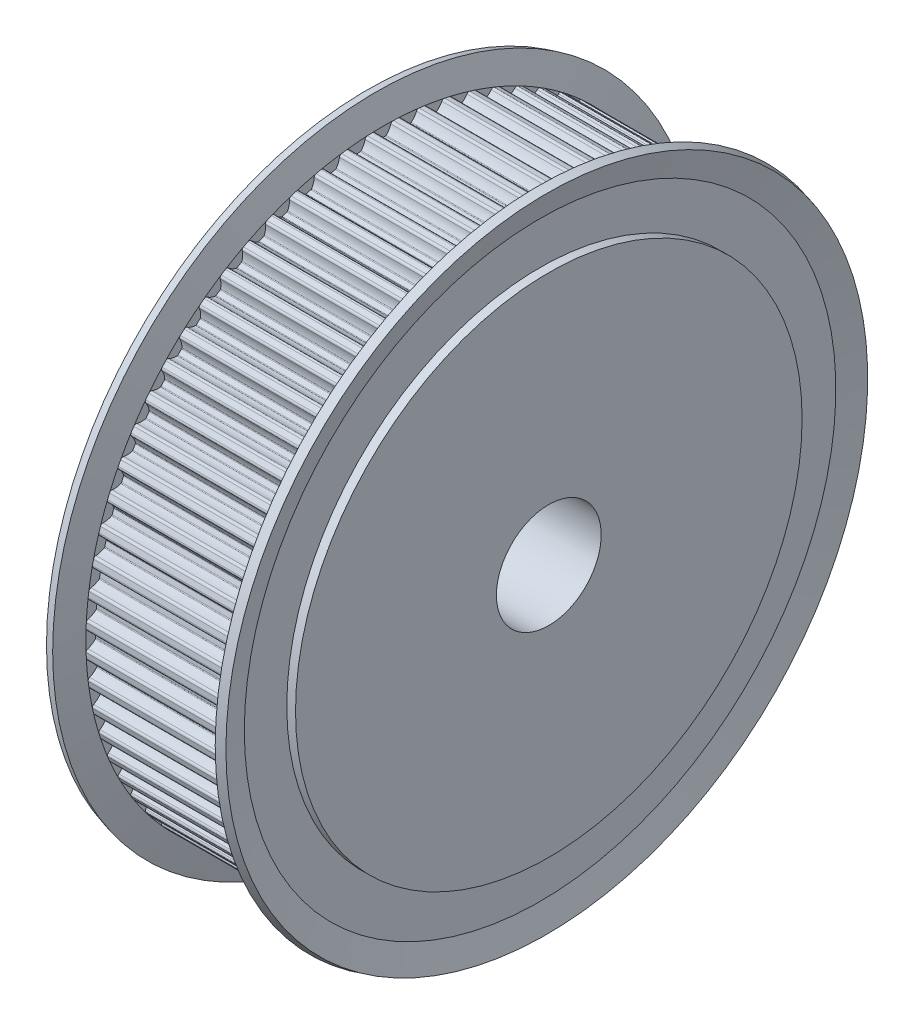
from build123d import *

# Parameters (mm, degrees)
SKETCH_2_W          = 21
SKETCH_2_H          = 6
SKETCH_3_R          = 38.995
CUT_EXTRUDE_1_DEPTH = 17


with BuildPart() as part:
    # ｽｹｯﾁ1 → 回転1 (revolve)
    with BuildSketch(Plane.XY):
        Polygon((0, 0), (0, 29), (1, 29), (1, 33.863347502), (0.22888685, 36.741180955), (1.194812677, 37), (2, 33.995), (19, 33.995), (19.805187323, 37), (20.77111315, 36.741180955), (20, 33.863347502), (20, 29), (21, 29), (21, 0), align=None)
    revolve(axis=Axis((21, 0, 0), (-1, 0, 0)))

    # ｽｹｯﾁ2 → ｶｯﾄ - 回転1 (revolve, cut)
    with BuildSketch(Plane.XY):
        with Locations((10.5, 3)):
            Rectangle(SKETCH_2_W, SKETCH_2_H)
    revolve(axis=Axis((21, 0, 0), (-1, 0, 0)), mode=Mode.SUBTRACT)

    # ｽｹｯﾁ3 → ｶｯﾄ - 押し出し1 (cut)
    with BuildSketch(Plane(origin=(2, 0, 0), x_dir=(0, 0, -1), z_dir=(1, 0, 0))):
        Circle(SKETCH_3_R)
        with BuildLine():
            ThreePointArc((-33.777168623, -0.911681599), (-33.922614353, -1.016968917), (-33.974202204, -1.18895314))
            ThreePointArc((-33.974202204, -1.18895314), (-33.962644297, -1.482840979), (-33.948544212, -1.776617823))
            ThreePointArc((-33.948544212, -1.776617823), (-33.882163306, -1.943451535), (-33.728094586, -2.035661844))
            ThreePointArc((-33.728094586, -2.035661844), (-33.250950848, -2.205234651), (-32.83260935, -2.490561611))
            ThreePointArc((-32.83260935, -2.490561611), (-32.797994707, -2.535862252), (-32.782784237, -2.590807344))
            ThreePointArc((-32.782784237, -2.590807344), (-32.759862676, -2.866116264), (-32.73462912, -3.141222911))
            ThreePointArc((-32.73462912, -3.141222911), (-32.740067244, -3.197974916), (-32.766289768, -3.248598454))
            ThreePointArc((-32.766289768, -3.248598454), (-33.128729197, -3.60223486), (-33.569178012, -3.852086595))
            ThreePointArc((-33.569178012, -3.852086595), (-33.704893882, -3.969649693), (-33.741296014, -4.145475642))
            ThreePointArc((-33.741296014, -4.145475642), (-33.704168075, -4.43723781), (-33.664517306, -4.728667842))
            ThreePointArc((-33.664517306, -4.728667842), (-33.583848484, -4.889081224), (-33.422329383, -4.967512671))
            ThreePointArc((-33.422329383, -4.967512671), (-32.93222222, -5.094854328), (-32.490604858, -5.342634543))
            ThreePointArc((-32.490604858, -5.342634543), (-32.452173557, -5.384745989), (-32.432232107, -5.43815645))
            ThreePointArc((-32.432232107, -5.43815645), (-32.385402958, -5.710420323), (-32.336288235, -5.982281187))
            ThreePointArc((-32.336288235, -5.982281187), (-32.336759592, -6.039290865), (-32.358470133, -6.092006878))
            ThreePointArc((-32.358470133, -6.092006878), (-32.688708926, -6.475886269), (-33.105705687, -6.763174885))
            ThreePointArc((-33.105705687, -6.763174885), (-33.230658816, -6.892119033), (-33.251598189, -7.070448561))
            ThreePointArc((-33.251598189, -7.070448561), (-33.189182784, -7.357864578), (-33.124283096, -7.644729844))
            ThreePointArc((-33.124283096, -7.644729844), (-33.029940296, -7.797502053), (-32.862200073, -7.861557728))
            ThreePointArc((-32.862200073, -7.861557728), (-32.362859356, -7.945699158), (-31.901327011, -8.154047007))
            ThreePointArc((-31.901327011, -8.154047007), (-31.859371701, -8.192648697), (-31.834851107, -8.244117901))
            ThreePointArc((-31.834851107, -8.244117901), (-31.764470885, -8.511263973), (-31.691848915, -8.77780937))
            ThreePointArc((-31.691848915, -8.77780937), (-31.68734954, -8.834643506), (-31.704383001, -8.889051453))
            ThreePointArc((-31.704383001, -8.889051453), (-31.999907843, -9.300252273), (-32.390278951, -9.622791331))
            ThreePointArc((-32.390278951, -9.622791331), (-32.503518375, -9.762135195), (-32.508835621, -9.941611117))
            ThreePointArc((-32.508835621, -9.941611117), (-32.421607769, -10.222493564), (-32.331953091, -10.502610835))
            ThreePointArc((-32.331953091, -10.502610835), (-32.224654318, -10.646579182), (-32.051969577, -10.695771583))
            ThreePointArc((-32.051969577, -10.695771583), (-31.547195595, -10.736072418), (-31.069260809, -10.903402246))
            ThreePointArc((-31.069260809, -10.903402246), (-31.024100792, -10.938200398), (-30.995187669, -10.987336637))
            ThreePointArc((-30.995187669, -10.987336637), (-30.90179195, -11.247332096), (-30.806215367, -11.506533786))
            ThreePointArc((-30.806215367, -11.506533786), (-30.796779693, -11.56275958), (-30.80900643, -11.618445115))
            ThreePointArc((-30.80900643, -11.618445115), (-31.067568184, -12.0538378), (-31.428342635, -12.409172525))
            ThreePointArc((-31.428342635, -12.409172525), (-31.529006529, -12.557855605), (-31.518661189, -12.73711199))
            ThreePointArc((-31.518661189, -12.73711199), (-31.407284746, -13.009323191), (-31.2935574, -13.280560616))
            ThreePointArc((-31.2935574, -13.280560616), (-31.174119263, -13.414629416), (-30.99780424, -13.448584158))
            ThreePointArc((-30.99780424, -13.448584158), (-30.491438626, -13.444737685), (-30.000738771, -13.569776011))
            ThreePointArc((-30.000738771, -13.569776011), (-29.952717742, -13.600505791), (-29.919632137, -13.646935107))
            ThreePointArc((-29.919632137, -13.646935107), (-29.803931719, -13.897801232), (-29.686127918, -14.147686533))
            ThreePointArc((-29.686127918, -14.147686533), (-29.67182775, -14.202875997), (-29.679154645, -14.259415261))
            ThreePointArc((-29.679154645, -14.259415261), (-29.89878552, -14.715686288), (-30.227217655, -15.101112423))
            ThreePointArc((-30.227217655, -15.101112423), (-30.314539909, -15.25800316), (-30.288610707, -15.435675769))
            ThreePointArc((-30.288610707, -15.435675769), (-30.153933318, -15.697144023), (-30.016998841, -15.957437311))
            ThreePointArc((-30.016998841, -15.957437311), (-29.886330337, -16.08058622), (-29.707726895, -16.099044887))
            ThreePointArc((-29.707726895, -16.099044887), (-29.203623396, -16.05108038), (-28.703892992, -16.132875587))
            ThreePointArc((-28.703892992, -16.132875587), (-28.653376423, -16.159303124), (-28.616370138, -16.20267216))
            ThreePointArc((-28.616370138, -16.20267216), (-28.479245572, -16.442499708), (-28.340111111, -16.681166842))
            ThreePointArc((-28.340111111, -16.681166842), (-28.32105529, -16.734899884), (-28.323426541, -16.791862514))
            ThreePointArc((-28.323426541, -16.791862514), (-28.502455004, -17.265539439), (-28.796045267, -17.678123706))
            ThreePointArc((-28.796045267, -17.678123706), (-28.869361332, -17.842028072), (-28.828045612, -18.016764725))
            ThreePointArc((-28.828045612, -18.016764725), (-28.671092251, -18.265500106), (-28.511992797, -18.512868274))
            ThreePointArc((-28.511992797, -18.512868274), (-28.371088391, -18.624160053), (-28.191555811, -18.626982163))
            ThreePointArc((-28.191555811, -18.626982163), (-27.693550959, -18.535264661), (-27.188593259, -18.573194239))
            ThreePointArc((-27.188593259, -18.573194239), (-27.135965609, -18.595118401), (-27.095320283, -18.635097095))
            ThreePointArc((-27.095320283, -18.635097095), (-26.93781517, -18.862060833), (-26.778408946, -19.0876934))
            ThreePointArc((-26.778408946, -19.0876934), (-26.754742496, -19.139561146), (-26.752140102, -19.196513683))
            ThreePointArc((-26.752140102, -19.196513683), (-26.889203644, -19.683991484), (-27.14571762, -20.120593821))
            ThreePointArc((-27.14571762, -20.120593821), (-27.204469487, -20.290264398), (-27.148081684, -20.460735223))
            ThreePointArc((-27.148081684, -20.460735223), (-26.970046861, -20.694844704), (-26.789993272, -20.92740513))
            ThreePointArc((-26.789993272, -20.92740513), (-26.639925332, -21.025992783), (-26.460829964, -21.013156858))
            ThreePointArc((-26.460829964, -21.013156858), (-25.97271388, -20.878384387), (-25.466371917, -20.872159667))
            ThreePointArc((-25.466371917, -20.872159667), (-25.412033713, -20.889413599), (-25.368058681, -20.925697689))
            ThreePointArc((-25.368058681, -20.925697689), (-25.191371729, -21.138070286), (-25.01290692, -21.348951085))
            ThreePointArc((-25.01290692, -21.348951085), (-24.984809955, -21.398558794), (-24.977253724, -21.455067799))
            ThreePointArc((-24.977253724, -21.455067799), (-25.071309207, -21.952636467), (-25.288794664, -22.409934061))
            ThreePointArc((-25.288794664, -22.409934061), (-25.332535204, -22.584079556), (-25.261504461, -22.748987172))
            ThreePointArc((-25.261504461, -22.748987172), (-25.063743129, -22.966689038), (-24.864105721, -23.182671798))
            ThreePointArc((-24.864105721, -23.182671798), (-24.706016355, -23.267805011), (-24.528721224, -23.239408742))
            ThreePointArc((-24.528721224, -23.239408742), (-24.054208764, -23.062607), (-23.550336105, -23.012275357))
            ThreePointArc((-23.550336105, -23.012275357), (-23.494700895, -23.024727746), (-23.447730834, -23.057041088))
            ThreePointArc((-23.447730834, -23.057041088), (-23.253206738, -23.253206261), (-23.057041569, -23.447730362))
            ThreePointArc((-23.057041569, -23.447730362), (-23.024727926, -23.494700483), (-23.012275364, -23.55033588))
            ThreePointArc((-23.012275364, -23.55033588), (-23.062606969, -24.054208629), (-23.239408718, -24.528721178))
            ThreePointArc((-23.239408718, -24.528721178), (-23.267805032, -24.706016236), (-23.182671936, -24.864105592))
            ThreePointArc((-23.182671936, -24.864105592), (-22.966689178, -25.063743001), (-22.748987313, -25.261504334))
            ThreePointArc((-22.748987313, -25.261504334), (-22.584079676, -25.332535194), (-22.409934104, -25.288794692))
            ThreePointArc((-22.409934104, -25.288794692), (-21.952636596, -25.071309249), (-21.455068018, -24.977253737))
            ThreePointArc((-21.455068018, -24.977253737), (-21.398559218, -24.984809812), (-21.348951598, -25.012906482))
            ThreePointArc((-21.348951598, -25.012906482), (-21.138070545, -25.191371512), (-20.925697689, -25.368058681))
            ThreePointArc((-20.925697689, -25.368058681), (-20.889413652, -25.412033614), (-20.872159693, -25.466371694))
            ThreePointArc((-20.872159693, -25.466371694), (-20.878384368, -25.972713748), (-21.013156842, -26.460829925))
            ThreePointArc((-21.013156842, -26.460829925), (-21.025992812, -26.63992522), (-20.92740528, -26.789993155))
            ThreePointArc((-20.92740528, -26.789993155), (-20.694844855, -26.970046745), (-20.460735375, -27.14808157))
            ThreePointArc((-20.460735375, -27.14808157), (-20.290264514, -27.204469488), (-20.120593854, -27.145717645))
            ThreePointArc((-20.120593854, -27.145717645), (-19.683991605, -26.889203695), (-19.196513902, -26.752140134))
            ThreePointArc((-19.196513902, -26.752140134), (-19.139561581, -26.75474239), (-19.087693949, -26.778408555))
            ThreePointArc((-19.087693949, -26.778408555), (-18.862061109, -26.937814976), (-18.635097095, -27.095320283))
            ThreePointArc((-18.635097095, -27.095320283), (-18.59511846, -27.135965519), (-18.573194282, -27.188593049))
            ThreePointArc((-18.573194282, -27.188593049), (-18.535264654, -27.693550822), (-18.626982145, -28.191555754))
            ThreePointArc((-18.626982145, -28.191555754), (-18.624160093, -28.371088278), (-18.512868425, -28.511992699))
            ThreePointArc((-18.512868425, -28.511992699), (-18.265500262, -28.671092152), (-18.016764886, -28.828045512))
            ThreePointArc((-18.016764886, -28.828045512), (-17.842028188, -28.869361343), (-17.678123736, -28.796045296))
            ThreePointArc((-17.678123736, -28.796045296), (-17.26553942, -28.502454994), (-16.791862432, -28.323426522))
            ThreePointArc((-16.791862432, -28.323426522), (-16.734900176, -28.321055246), (-16.681167424, -28.340110769))
            ThreePointArc((-16.681167424, -28.340110769), (-16.4425, -28.479245403), (-16.20267216, -28.616370138))
            ThreePointArc((-16.20267216, -28.616370138), (-16.159303151, -28.653376389), (-16.132875613, -28.703892908))
            ThreePointArc((-16.132875613, -28.703892908), (-16.051080382, -29.203623322), (-16.099044874, -29.707726837))
            ThreePointArc((-16.099044874, -29.707726837), (-16.080586272, -29.886330223), (-15.957437479, -30.016998752))
            ThreePointArc((-15.957437479, -30.016998752), (-15.697144191, -30.15393323), (-15.435675938, -30.288610621))
            ThreePointArc((-15.435675938, -30.288610621), (-15.258003253, -30.314539926), (-15.101112423, -30.227217655))
            ThreePointArc((-15.101112423, -30.227217655), (-14.715686195, -29.89878546), (-14.25941505, -29.679154575))
            ThreePointArc((-14.25941505, -29.679154575), (-14.202876223, -29.671827735), (-14.147687142, -29.686127628))
            ThreePointArc((-14.147687142, -29.686127628), (-13.897801537, -29.803931577), (-13.646935107, -29.919632137))
            ThreePointArc((-13.646935107, -29.919632137), (-13.600505865, -29.952717665), (-13.56977609, -30.000738572))
            ThreePointArc((-13.56977609, -30.000738572), (-13.444737702, -30.491438487), (-13.448584149, -30.997804174))
            ThreePointArc((-13.448584149, -30.997804174), (-13.41462948, -31.174119151), (-13.280560791, -31.293557326))
            ThreePointArc((-13.280560791, -31.293557326), (-13.009323371, -31.407284671), (-12.737112175, -31.518661114))
            ThreePointArc((-12.737112175, -31.518661114), (-12.557855701, -31.529006556), (-12.409172525, -31.428342635))
            ThreePointArc((-12.409172525, -31.428342635), (-12.053837714, -31.067568116), (-11.618444913, -30.809006343))
            ThreePointArc((-11.618444913, -30.809006343), (-11.562759807, -30.796779699), (-11.506534418, -30.806215131))
            ThreePointArc((-11.506534418, -30.806215131), (-11.247332413, -30.901791835), (-10.987336637, -30.995187669))
            ThreePointArc((-10.987336637, -30.995187669), (-10.938200432, -31.024100762), (-10.903402286, -31.069260728))
            ThreePointArc((-10.903402286, -31.069260728), (-10.736072434, -31.547195518), (-10.695771579, -32.051969511))
            ThreePointArc((-10.695771579, -32.051969511), (-10.646579255, -32.224654212), (-10.502611015, -32.331953032))
            ThreePointArc((-10.502611015, -32.331953032), (-10.222493745, -32.421607712), (-9.941611298, -32.508835565))
            ThreePointArc((-9.941611298, -32.508835565), (-9.762135284, -32.503518408), (-9.622791331, -32.390278951))
            ThreePointArc((-9.622791331, -32.390278951), (-9.300252247, -31.999907819), (-8.889051391, -31.704382968))
            ThreePointArc((-8.889051391, -31.704382968), (-8.834643807, -31.687349574), (-8.77781002, -31.691848735))
            ThreePointArc((-8.77781002, -31.691848735), (-8.511264298, -31.764470798), (-8.244117901, -31.834851107))
            ThreePointArc((-8.244117901, -31.834851107), (-8.192648733, -31.859371675), (-8.154047054, -31.901326935))
            ThreePointArc((-8.154047054, -31.901326935), (-7.94569918, -32.362859285), (-7.86155773, -32.862200013))
            ThreePointArc((-7.86155773, -32.862200013), (-7.797502014, -33.029940342), (-7.644729668, -33.124283136))
            ThreePointArc((-7.644729668, -33.124283136), (-7.357864588, -33.189182781), (-7.070448756, -33.251598148))
            ThreePointArc((-7.070448756, -33.251598148), (-6.892119123, -33.230658859), (-6.763174885, -33.105705687))
            ThreePointArc((-6.763174885, -33.105705687), (-6.475886248, -32.688708903), (-6.092006826, -32.358470099))
            ThreePointArc((-6.092006826, -32.358470099), (-6.039290835, -32.336759585), (-5.982281187, -32.336288235))
            ThreePointArc((-5.982281187, -32.336288235), (-5.710420323, -32.385402958), (-5.43815645, -32.432232107))
            ThreePointArc((-5.43815645, -32.432232107), (-5.384746029, -32.452173533), (-5.342634599, -32.490604782))
            ThreePointArc((-5.342634599, -32.490604782), (-5.094854358, -32.932222145), (-4.96751268, -33.422329317))
            ThreePointArc((-4.96751268, -33.422329317), (-4.889081184, -33.583848524), (-4.728667664, -33.664517331))
            ThreePointArc((-4.728667664, -33.664517331), (-4.437237815, -33.704168074), (-4.14547583, -33.741295991))
            ThreePointArc((-4.14547583, -33.741295991), (-3.969649775, -33.70489393), (-3.852086595, -33.569178012))
            ThreePointArc((-3.852086595, -33.569178012), (-3.602234844, -33.128729175), (-3.24859841, -32.766289734))
            ThreePointArc((-3.24859841, -32.766289734), (-3.197975213, -32.740067332), (-3.141223582, -32.734629056))
            ThreePointArc((-3.141223582, -32.734629056), (-2.866116936, -32.759862617), (-2.590808017, -32.782784183))
            ThreePointArc((-2.590808017, -32.782784183), (-2.535862458, -32.797994605), (-2.490561468, -32.832609511))
            ThreePointArc((-2.490561468, -32.832609511), (-2.205234616, -33.250950918), (-2.035661857, -33.728094528))
            ThreePointArc((-2.035661857, -33.728094528), (-1.943451489, -33.882163345), (-1.776617644, -33.948544221))
            ThreePointArc((-1.776617644, -33.948544221), (-1.482840984, -33.962644297), (-1.18895333, -33.974202198))
            ThreePointArc((-1.18895333, -33.974202198), (-1.016968994, -33.922614408), (-0.911681599, -33.777168623))
            ThreePointArc((-0.911681599, -33.777168623), (-0.701168253, -33.316619809), (-0.380466189, -32.924738112))
            ThreePointArc((-0.380466189, -32.924738112), (-0.332321063, -32.894203395), (-0.276259369, -32.883839584))
            ThreePointArc((-0.276259369, -32.883839584), (-3.37e-07, -32.885), (0.276258695, -32.883839589))
            ThreePointArc((0.276258695, -32.883839589), (0.332320839, -32.894203307), (0.38046633, -32.924738245))
            ThreePointArc((0.38046633, -32.924738245), (0.701168287, -33.316619863), (0.911681579, -33.77716856))
            ThreePointArc((0.911681579, -33.77716856), (1.016969036, -33.922614437), (1.188953498, -33.974202192))
            ThreePointArc((1.188953498, -33.974202192), (1.482841158, -33.962644289), (1.776617823, -33.948544212))
            ThreePointArc((1.776617823, -33.948544212), (1.943451535, -33.882163306), (2.035661844, -33.728094586))
            ThreePointArc((2.035661844, -33.728094586), (2.205234649, -33.250950852), (2.490561605, -32.832609357))
            ThreePointArc((2.490561605, -32.832609357), (2.535862248, -32.797994709), (2.590807344, -32.782784237))
            ThreePointArc((2.590807344, -32.782784237), (2.866116264, -32.759862676), (3.141222911, -32.73462912))
            ThreePointArc((3.141222911, -32.73462912), (3.197974975, -32.740067262), (3.24859855, -32.766289845))
            ThreePointArc((3.24859855, -32.766289845), (3.602234875, -33.128729217), (3.852086567, -33.569177944))
            ThreePointArc((3.852086567, -33.569177944), (3.969649816, -33.704893955), (4.145475998, -33.74129597))
            ThreePointArc((4.145475998, -33.74129597), (4.437237988, -33.704168051), (4.728667842, -33.664517306))
            ThreePointArc((4.728667842, -33.664517306), (4.889081224, -33.583848484), (4.967512671, -33.422329383))
            ThreePointArc((4.967512671, -33.422329383), (5.09485433, -32.932222216), (5.342634548, -32.490604851))
            ThreePointArc((5.342634548, -32.490604851), (5.384745993, -32.452173555), (5.43815645, -32.432232107))
            ThreePointArc((5.43815645, -32.432232107), (5.710419991, -32.385403016), (5.982280524, -32.336288357))
            ThreePointArc((5.982280524, -32.336288357), (6.039290596, -32.336759537), (6.092006982, -32.358470201))
            ThreePointArc((6.092006982, -32.358470201), (6.475886286, -32.688708945), (6.763174852, -33.105705622))
            ThreePointArc((6.763174852, -33.105705622), (6.892119167, -33.230658879), (7.070448921, -33.251598113))
            ThreePointArc((7.070448921, -33.251598113), (7.357864758, -33.189182744), (7.644729844, -33.124283096))
            ThreePointArc((7.644729844, -33.124283096), (7.797502053, -33.029940296), (7.861557728, -32.862200073))
            ThreePointArc((7.861557728, -32.862200073), (7.945699158, -32.362859355), (8.154047009, -31.901327008))
            ThreePointArc((8.154047009, -31.901327008), (8.192648698, -31.8593717), (8.244117901, -31.834851107))
            ThreePointArc((8.244117901, -31.834851107), (8.511263973, -31.764470885), (8.77780937, -31.691848915))
            ThreePointArc((8.77780937, -31.691848915), (8.834643567, -31.687349547), (8.88905156, -31.704383059))
            ThreePointArc((8.88905156, -31.704383059), (9.300252291, -31.999907859), (9.622791292, -32.390278889))
            ThreePointArc((9.622791292, -32.390278889), (9.762135329, -32.503518424), (9.94161146, -32.508835516))
            ThreePointArc((9.94161146, -32.508835516), (10.222493735, -32.421607715), (10.502610835, -32.331953091))
            ThreePointArc((10.502610835, -32.331953091), (10.646579182, -32.224654318), (10.695771583, -32.051969577))
            ThreePointArc((10.695771583, -32.051969577), (10.736072419, -31.547195592), (10.903402248, -31.069260804))
            ThreePointArc((10.903402248, -31.069260804), (10.938200401, -31.02410079), (10.987336637, -30.995187669))
            ThreePointArc((10.987336637, -30.995187669), (11.247332096, -30.90179195), (11.506533786, -30.806215367))
            ThreePointArc((11.506533786, -30.806215367), (11.562759565, -30.796779693), (11.618445087, -30.809006418))
            ThreePointArc((11.618445087, -30.809006418), (12.053837759, -31.067568152), (12.409172481, -31.428342577))
            ThreePointArc((12.409172481, -31.428342577), (12.557855584, -31.529006524), (12.737112019, -31.518661177))
            ThreePointArc((12.737112019, -31.518661177), (13.009323205, -31.40728474), (13.280560616, -31.2935574))
            ThreePointArc((13.280560616, -31.2935574), (13.414629416, -31.174119263), (13.448584158, -30.99780424))
            ThreePointArc((13.448584158, -30.99780424), (13.444737685, -30.491438623), (13.569776013, -30.000738765))
            ThreePointArc((13.569776013, -30.000738765), (13.600505793, -29.95271774), (13.646935107, -29.919632137))
            ThreePointArc((13.646935107, -29.919632137), (13.897801232, -29.803931719), (14.147686533, -29.686127918))
            ThreePointArc((14.147686533, -29.686127918), (14.202875984, -29.67182775), (14.259415236, -29.679154636))
            ThreePointArc((14.259415236, -29.679154636), (14.715686242, -29.89878549), (15.101112366, -30.227217592))
            ThreePointArc((15.101112366, -30.227217592), (15.258003129, -30.314539903), (15.435675788, -30.288610697))
            ThreePointArc((15.435675788, -30.288610697), (15.697144032, -30.153933313), (15.957437311, -30.016998841))
            ThreePointArc((15.957437311, -30.016998841), (16.08058622, -29.886330337), (16.099044887, -29.707726895))
            ThreePointArc((16.099044887, -29.707726895), (16.05108038, -29.203623391), (16.13287559, -28.703892984))
            ThreePointArc((16.13287559, -28.703892984), (16.159303126, -28.653376419), (16.20267216, -28.616370138))
            ThreePointArc((16.20267216, -28.616370138), (16.442499708, -28.479245572), (16.681166842, -28.340111111))
            ThreePointArc((16.681166842, -28.340111111), (16.734899937, -28.321055282), (16.791862618, -28.323426566))
            ThreePointArc((16.791862618, -28.323426566), (17.265539467, -28.502455019), (17.678123675, -28.796045239))
            ThreePointArc((17.678123675, -28.796045239), (17.842028062, -28.869361331), (18.016764743, -28.828045601))
            ThreePointArc((18.016764743, -28.828045601), (18.265500115, -28.671092246), (18.512868274, -28.511992797))
            ThreePointArc((18.512868274, -28.511992797), (18.624160053, -28.371088391), (18.626982163, -28.191555811))
            ThreePointArc((18.626982163, -28.191555811), (18.535264653, -27.693550814), (18.573194298, -27.188592973))
            ThreePointArc((18.573194298, -27.188592973), (18.595118482, -27.135965487), (18.635097095, -27.095320283))
            ThreePointArc((18.635097095, -27.095320283), (18.862060833, -26.93781517), (19.0876934, -26.778408946))
            ThreePointArc((19.0876934, -26.778408946), (19.139561162, -26.754742492), (19.196513716, -26.752140107))
            ThreePointArc((19.196513716, -26.752140107), (19.683991477, -26.88920364), (20.120593782, -27.145717589))
            ThreePointArc((20.120593782, -27.145717589), (20.290264553, -27.204469489), (20.46073551, -27.148081468))
            ThreePointArc((20.46073551, -27.148081468), (20.694844846, -26.970046752), (20.92740513, -26.789993272))
            ThreePointArc((20.92740513, -26.789993272), (21.025992783, -26.639925332), (21.013156858, -26.460829964))
            ThreePointArc((21.013156858, -26.460829964), (20.878384366, -25.972713733), (20.872159701, -25.466371621))
            ThreePointArc((20.872159701, -25.466371621), (20.88941367, -25.412033582), (20.925697689, -25.368058681))
            ThreePointArc((20.925697689, -25.368058681), (21.138070286, -25.191371729), (21.348951085, -25.01290692))
            ThreePointArc((21.348951085, -25.01290692), (21.398558834, -24.984809941), (21.455067884, -24.977253729))
            ThreePointArc((21.455067884, -24.977253729), (21.952636488, -25.071309214), (22.409934027, -25.288794643))
            ThreePointArc((22.409934027, -25.288794643), (22.584079714, -25.332535191), (22.748987438, -25.261504221))
            ThreePointArc((22.748987438, -25.261504221), (22.96668917, -25.063743008), (23.182671798, -24.864105721))
            ThreePointArc((23.182671798, -24.864105721), (23.267805011, -24.706016355), (23.239408742, -24.528721224))
            ThreePointArc((23.239408742, -24.528721224), (23.062606966, -24.054208617), (23.012275366, -23.550335804))
            ThreePointArc((23.012275366, -23.550335804), (23.024727806, -23.494700757), (23.057041088, -23.447730834))
            ThreePointArc((23.057041088, -23.447730834), (23.253206261, -23.253206738), (23.447730362, -23.057041569))
            ThreePointArc((23.447730362, -23.057041569), (23.494700505, -23.024727916), (23.55033593, -23.012275362))
            ThreePointArc((23.55033593, -23.012275362), (24.054208634, -23.06260697), (24.528721142, -23.239408699))
            ThreePointArc((24.528721142, -23.239408699), (24.706016384, -23.267805006), (24.864105824, -23.182671687))
            ThreePointArc((24.864105824, -23.182671687), (25.063743116, -22.966689052), (25.261504334, -22.748987313))
            ThreePointArc((25.261504334, -22.748987313), (25.332535194, -22.584079676), (25.288794692, -22.409934104))
            ThreePointArc((25.288794692, -22.409934104), (25.071309202, -21.952636451), (24.97725372, -21.455067715))
            ThreePointArc((24.97725372, -21.455067715), (24.984809861, -21.398559074), (25.012906482, -21.348951598))
            ThreePointArc((25.012906482, -21.348951598), (25.191371295, -21.138070803), (25.368058252, -20.925698209))
            ThreePointArc((25.368058252, -20.925698209), (25.41203333, -20.889413807), (25.466371722, -20.872159689))
            ThreePointArc((25.466371722, -20.872159689), (25.972713741, -20.878384367), (26.460829886, -21.013156826))
            ThreePointArc((26.460829886, -21.013156826), (26.639925218, -21.025992812), (26.789993179, -20.927405249))
            ThreePointArc((26.789993179, -20.927405249), (26.970046757, -20.694844839), (27.14808157, -20.460735375))
            ThreePointArc((27.14808157, -20.460735375), (27.204469488, -20.290264514), (27.145717645, -20.120593854))
            ThreePointArc((27.145717645, -20.120593854), (26.889203638, -19.68399147), (26.752140092, -19.196513611))
            ThreePointArc((26.752140092, -19.196513611), (26.754742425, -19.139561438), (26.778408555, -19.087693949))
            ThreePointArc((26.778408555, -19.087693949), (26.937814783, -18.862061386), (27.095319901, -18.635097651))
            ThreePointArc((27.095319901, -18.635097651), (27.135965247, -18.595118641), (27.188593069, -18.573194278))
            ThreePointArc((27.188593069, -18.573194278), (27.69355082, -18.535264654), (28.19155573, -18.626982138))
            ThreePointArc((28.19155573, -18.626982138), (28.371088423, -18.624160042), (28.511992879, -18.512868147))
            ThreePointArc((28.511992879, -18.512868147), (28.671092241, -18.265500122), (28.828045512, -18.016764886))
            ThreePointArc((28.828045512, -18.016764886), (28.869361343, -17.842028188), (28.796045296, -17.678123736))
            ThreePointArc((28.796045296, -17.678123736), (28.502454996, -17.265539424), (28.323426524, -16.791862441))
            ThreePointArc((28.323426524, -16.791862441), (28.321055246, -16.73490018), (28.340110769, -16.681167424))
            ThreePointArc((28.340110769, -16.681167424), (28.479245235, -16.442500292), (28.616369806, -16.202672747))
            ThreePointArc((28.616369806, -16.202672747), (28.653376086, -16.159303392), (28.703892812, -16.132875641))
            ThreePointArc((28.703892812, -16.132875641), (29.20362326, -16.051080385), (29.707726813, -16.099044868))
            ThreePointArc((29.707726813, -16.099044868), (29.886330236, -16.080586266), (30.016998777, -15.957437433))
            ThreePointArc((30.016998777, -15.957437433), (30.153933242, -15.697144168), (30.288610621, -15.435675938))
            ThreePointArc((30.288610621, -15.435675938), (30.314539926, -15.258003253), (30.227217655, -15.101112423))
            ThreePointArc((30.227217655, -15.101112423), (29.898785463, -14.715686199), (29.679154578, -14.259415059))
            ThreePointArc((29.679154578, -14.259415059), (29.671827735, -14.202876227), (29.686127628, -14.147687142))
            ThreePointArc((29.686127628, -14.147687142), (29.803931434, -13.897801843), (29.919631857, -13.64693572))
            ThreePointArc((29.919631857, -13.64693572), (29.952717427, -13.600506091), (30.00073859, -13.569776083))
            ThreePointArc((30.00073859, -13.569776083), (30.491438487, -13.444737702), (30.997804156, -13.448584146))
            ThreePointArc((30.997804156, -13.448584146), (31.174119161, -13.414629474), (31.293557341, -13.280560755))
            ThreePointArc((31.293557341, -13.280560755), (31.407284679, -13.009323353), (31.518661114, -12.737112175))
            ThreePointArc((31.518661114, -12.737112175), (31.529006556, -12.557855701), (31.428342635, -12.409172525))
            ThreePointArc((31.428342635, -12.409172525), (31.06756812, -12.053837719), (30.809006348, -11.618444924))
            ThreePointArc((30.809006348, -11.618444924), (30.796779699, -11.562759814), (30.806215131, -11.506534418))
            ThreePointArc((30.806215131, -11.506534418), (30.901791719, -11.24733273), (30.995187444, -10.987337272))
            ThreePointArc((30.995187444, -10.987337272), (31.024100504, -10.938200725), (31.069260634, -10.903402334))
            ThreePointArc((31.069260634, -10.903402334), (31.547195458, -10.736072447), (32.051969493, -10.695771578))
            ThreePointArc((32.051969493, -10.695771578), (32.224654221, -10.646579249), (32.331953044, -10.502610978))
            ThreePointArc((32.331953044, -10.502610978), (32.421607718, -10.222493726), (32.508835565, -9.941611298))
            ThreePointArc((32.508835565, -9.941611298), (32.503518408, -9.762135284), (32.390278951, -9.622791331))
            ThreePointArc((32.390278951, -9.622791331), (31.999907821, -9.30025225), (31.704382971, -8.889051397))
            ThreePointArc((31.704382971, -8.889051397), (31.687349574, -8.83464381), (31.691848735, -8.77781002))
            ThreePointArc((31.691848735, -8.77781002), (31.76447071, -8.511264624), (31.834850938, -8.244118554))
            ThreePointArc((31.834850938, -8.244118554), (31.859371444, -8.192649045), (31.901326848, -8.154047107))
            ThreePointArc((31.901326848, -8.154047107), (32.362859224, -7.945699198), (32.862199989, -7.861557731))
            ThreePointArc((32.862199989, -7.861557731), (33.029940316, -7.797502036), (33.124283127, -7.644729709))
            ThreePointArc((33.124283127, -7.644729709), (33.189182777, -7.357864609), (33.251598148, -7.070448756))
            ThreePointArc((33.251598148, -7.070448756), (33.230658859, -6.892119123), (33.105705687, -6.763174885))
            ThreePointArc((33.105705687, -6.763174885), (32.688708904, -6.475886249), (32.3584701, -6.092006829))
            ThreePointArc((32.3584701, -6.092006829), (32.336759586, -6.039290836), (32.336288235, -5.982281187))
            ThreePointArc((32.336288235, -5.982281187), (32.385402899, -5.710420655), (32.432231995, -5.438157115))
            ThreePointArc((32.432231995, -5.438157115), (32.45217333, -5.384746361), (32.490604699, -5.342634661))
            ThreePointArc((32.490604699, -5.342634661), (32.932222089, -5.094854381), (33.4223293, -4.967512682))
            ThreePointArc((33.4223293, -4.967512682), (33.583848503, -4.889081205), (33.664517325, -4.728667706))
            ThreePointArc((33.664517325, -4.728667706), (33.704168071, -4.437237836), (33.741295991, -4.14547583))
            ThreePointArc((33.741295991, -4.14547583), (33.70489393, -3.969649775), (33.569178012, -3.852086595))
            ThreePointArc((33.569178012, -3.852086595), (33.128729175, -3.602234844), (32.766289734, -3.24859841))
            ThreePointArc((32.766289734, -3.24859841), (32.740067332, -3.197975213), (32.734629056, -3.141223582))
            ThreePointArc((32.734629056, -3.141223582), (32.759862647, -2.8661166), (32.782784237, -2.590807344))
            ThreePointArc((32.782784237, -2.590807344), (32.79799473, -2.535862207), (32.832609426, -2.490561543))
            ThreePointArc((32.832609426, -2.490561543), (33.250950856, -2.205234647), (33.728094503, -2.035661862))
            ThreePointArc((33.728094503, -2.035661862), (33.882163324, -1.943451514), (33.948544219, -1.776617686))
            ThreePointArc((33.948544219, -1.776617686), (33.962644296, -1.482841005), (33.974202198, -1.18895333))
            ThreePointArc((33.974202198, -1.18895333), (33.922614408, -1.016968994), (33.777168623, -0.911681599))
            ThreePointArc((33.777168623, -0.911681599), (33.316619811, -0.701168254), (32.924738115, -0.380466191))
            ThreePointArc((32.924738115, -0.380466191), (32.894203395, -0.332321065), (32.883839584, -0.276259369))
            ThreePointArc((32.883839584, -0.276259369), (32.885, 0), (32.883839584, 0.276259369))
            ThreePointArc((32.883839584, 0.276259369), (32.894203415, 0.332321115), (32.924738188, 0.380466269))
            ThreePointArc((32.924738188, 0.380466269), (33.31661982, 0.70116826), (33.777168543, 0.911681574))
            ThreePointArc((33.777168543, 0.911681574), (33.922614419, 1.01696901), (33.974202194, 1.188953453))
            ThreePointArc((33.974202194, 1.188953453), (33.96264429, 1.482841135), (33.948544212, 1.776617823))
            ThreePointArc((33.948544212, 1.776617823), (33.882163306, 1.943451535), (33.728094586, 2.035661844))
            ThreePointArc((33.728094586, 2.035661844), (33.250950854, 2.205234648), (32.832609359, 2.490561603))
            ThreePointArc((32.832609359, 2.490561603), (32.79799471, 2.535862246), (32.782784237, 2.590807344))
            ThreePointArc((32.782784237, 2.590807344), (32.759862647, 2.8661166), (32.734629056, 3.141223582))
            ThreePointArc((32.734629056, 3.141223582), (32.740067348, 3.197975269), (32.766289807, 3.248598502))
            ThreePointArc((32.766289807, 3.248598502), (33.128729188, 3.602234854), (33.569177934, 3.852086563))
            ThreePointArc((33.569177934, 3.852086563), (33.704893936, 3.969649784), (33.741295978, 4.145475936))
            ThreePointArc((33.741295978, 4.145475936), (33.704168055, 4.437237957), (33.664517306, 4.728667842))
            ThreePointArc((33.664517306, 4.728667842), (33.583848484, 4.889081224), (33.422329383, 4.967512671))
            ThreePointArc((33.422329383, 4.967512671), (32.932222082, 5.094854384), (32.490604619, 5.342634721))
            ThreePointArc((32.490604619, 5.342634721), (32.452173479, 5.384746116), (32.432232107, 5.43815645))
            ThreePointArc((32.432232107, 5.43815645), (32.385402958, 5.710420323), (32.336288235, 5.982281187))
            ThreePointArc((32.336288235, 5.982281187), (32.336759597, 6.039290894), (32.358470165, 6.092006927))
            ThreePointArc((32.358470165, 6.092006927), (32.688708917, 6.47588626), (33.105705612, 6.763174847))
            ThreePointArc((33.105705612, 6.763174847), (33.230658863, 6.892119134), (33.251598126, 7.070448861))
            ThreePointArc((33.251598126, 7.070448861), (33.189182751, 7.357864728), (33.124283096, 7.644729844))
            ThreePointArc((33.124283096, 7.644729844), (33.029940296, 7.797502053), (32.862200073, 7.861557728))
            ThreePointArc((32.862200073, 7.861557728), (32.362859215, 7.945699201), (31.90132676, 8.154047162))
            ThreePointArc((31.90132676, 8.154047162), (31.859371614, 8.192648816), (31.834851107, 8.244117901))
            ThreePointArc((31.834851107, 8.244117901), (31.764470798, 8.511264298), (31.691848735, 8.77781002))
            ThreePointArc((31.691848735, 8.77781002), (31.687349579, 8.834643857), (31.704383016, 8.88905148))
            ThreePointArc((31.704383016, 8.88905148), (31.999907828, 9.300252258), (32.390278889, 9.622791292))
            ThreePointArc((32.390278889, 9.622791292), (32.50351841, 9.762135291), (32.50883554, 9.941611381))
            ThreePointArc((32.50883554, 9.941611381), (32.421607728, 10.222493696), (32.331953091, 10.502610835))
            ThreePointArc((32.331953091, 10.502610835), (32.224654318, 10.646579182), (32.051969577, 10.695771583))
            ThreePointArc((32.051969577, 10.695771583), (31.547195449, 10.736072449), (31.069260543, 10.903402379))
            ThreePointArc((31.069260543, 10.903402379), (31.024100693, 10.93820051), (30.995187669, 10.987336637))
            ThreePointArc((30.995187669, 10.987336637), (30.901791835, 11.247332413), (30.806215131, 11.506534418))
            ThreePointArc((30.806215131, 11.506534418), (30.796779701, 11.562759867), (30.80900639, 11.618445023))
            ThreePointArc((30.80900639, 11.618445023), (31.067568127, 12.053837728), (31.428342568, 12.409172474))
            ThreePointArc((31.428342568, 12.409172474), (31.529006533, 12.557855618), (31.518661147, 12.737112095))
            ThreePointArc((31.518661147, 12.737112095), (31.407284724, 13.009323243), (31.2935574, 13.280560616))
            ThreePointArc((31.2935574, 13.280560616), (31.174119263, 13.414629416), (30.99780424, 13.448584158))
            ThreePointArc((30.99780424, 13.448584158), (30.491438478, 13.444737703), (30.000738494, 13.569776121))
            ThreePointArc((30.000738494, 13.569776121), (29.952717629, 13.600505899), (29.919632131, 13.646935119))
            ThreePointArc((29.919632131, 13.646935119), (29.803931574, 13.897801544), (29.686127628, 14.147687142))
            ThreePointArc((29.686127628, 14.147687142), (29.671827732, 14.202876283), (29.679154613, 14.259415166))
            ThreePointArc((29.679154613, 14.259415166), (29.89878547, 14.715686211), (30.227217592, 15.101112366))
            ThreePointArc((30.227217592, 15.101112366), (30.31453991, 15.258003169), (30.28861066, 15.435675861))
            ThreePointArc((30.28861066, 15.435675861), (30.153933294, 15.697144068), (30.016998841, 15.957437311))
            ThreePointArc((30.016998841, 15.957437311), (29.886330337, 16.08058622), (29.707726895, 16.099044887))
            ThreePointArc((29.707726895, 16.099044887), (29.203623248, 16.051080385), (28.70389271, 16.132875672))
            ThreePointArc((28.70389271, 16.132875672), (28.653376302, 16.15930322), (28.616370131, 16.202672172))
            ThreePointArc((28.616370131, 16.202672172), (28.4792454, 16.442500006), (28.340110769, 16.681167424))
            ThreePointArc((28.340110769, 16.681167424), (28.321055237, 16.734900239), (28.323426551, 16.791862557))
            ThreePointArc((28.323426551, 16.791862557), (28.502455003, 17.265539437), (28.796045234, 17.678123669))
            ThreePointArc((28.796045234, 17.678123669), (28.869361334, 17.842028099), (28.828045558, 18.016764813))
            ThreePointArc((28.828045558, 18.016764813), (28.671092224, 18.265500149), (28.511992797, 18.512868274))
            ThreePointArc((28.511992797, 18.512868274), (28.371088391, 18.624160053), (28.191555811, 18.626982163))
            ThreePointArc((28.191555811, 18.626982163), (27.693550812, 18.535264653), (27.18859297, 18.573194298))
            ThreePointArc((27.18859297, 18.573194298), (27.135965486, 18.595118482), (27.095320283, 18.635097095))
            ThreePointArc((27.095320283, 18.635097095), (26.937814976, 18.862061109), (26.778408555, 19.087693949))
            ThreePointArc((26.778408555, 19.087693949), (26.754742408, 19.139561507), (26.752140112, 19.196513751))
            ThreePointArc((26.752140112, 19.196513751), (26.889203647, 19.683991492), (27.145717589, 20.120593782))
            ThreePointArc((27.145717589, 20.120593782), (27.204469488, 20.290264425), (27.148081622, 20.460735306))
            ThreePointArc((27.148081622, 20.460735306), (26.97004683, 20.694844745), (26.789993272, 20.92740513))
            ThreePointArc((26.789993272, 20.92740513), (26.639925332, 21.025992783), (26.460829964, 21.013156858))
            ThreePointArc((26.460829964, 21.013156858), (25.972713731, 20.878384365), (25.466371618, 20.872159702))
            ThreePointArc((25.466371618, 20.872159702), (25.412033581, 20.88941367), (25.368058681, 20.925697689))
            ThreePointArc((25.368058681, 20.925697689), (25.191371512, 21.138070545), (25.012906482, 21.348951598))
            ThreePointArc((25.012906482, 21.348951598), (24.984809841, 21.398559133), (24.977253727, 21.45506784))
            ThreePointArc((24.977253727, 21.45506784), (25.071309207, 21.952636467), (25.288794643, 22.409934027))
            ThreePointArc((25.288794643, 22.409934027), (25.332535195, 22.584079674), (25.261504276, 22.748987378))
            ThreePointArc((25.261504276, 22.748987378), (25.063743036, 22.96668914), (24.864105721, 23.182671798))
            ThreePointArc((24.864105721, 23.182671798), (24.706016355, 23.267805011), (24.528721224, 23.239408742))
            ThreePointArc((24.528721224, 23.239408742), (24.054208619, 23.062606966), (23.550335807, 23.012275366))
            ThreePointArc((23.550335807, 23.012275366), (23.494700752, 23.024727808), (23.447730825, 23.057041098))
            ThreePointArc((23.447730825, 23.057041098), (23.253206494, 23.253206504), (23.057041088, 23.447730834))
            ThreePointArc((23.057041088, 23.447730834), (23.024727785, 23.494700806), (23.012275363, 23.550335911))
            ThreePointArc((23.012275363, 23.550335911), (23.062606968, 24.054208625), (23.239408699, 24.528721142))
            ThreePointArc((23.239408699, 24.528721142), (23.267805012, 24.706016353), (23.182671734, 24.864105781))
            ThreePointArc((23.182671734, 24.864105781), (22.966689076, 25.063743094), (22.748987313, 25.261504334))
            ThreePointArc((22.748987313, 25.261504334), (22.584079676, 25.332535194), (22.409934104, 25.288794692))
            ThreePointArc((22.409934104, 25.288794692), (21.952636453, 25.071309202), (21.455067718, 24.97725372))
            ThreePointArc((21.455067718, 24.97725372), (21.398559068, 24.984809862), (21.348951587, 25.012906491))
            ThreePointArc((21.348951587, 25.012906491), (21.138070539, 25.191371516), (20.925697689, 25.368058681))
            ThreePointArc((20.925697689, 25.368058681), (20.889413641, 25.412033634), (20.872159688, 25.466371739))
            ThreePointArc((20.872159688, 25.466371739), (20.878384368, 25.972713746), (21.013156823, 26.460829879))
            ThreePointArc((21.013156823, 26.460829879), (21.025992805, 26.639925245), (20.927405199, 26.789993218))
            ThreePointArc((20.927405199, 26.789993218), (20.694844814, 26.970046777), (20.460735375, 27.14808157))
            ThreePointArc((20.460735375, 27.14808157), (20.290264514, 27.204469488), (20.120593854, 27.145717645))
            ThreePointArc((20.120593854, 27.145717645), (19.683991468, 26.889203637), (19.196513608, 26.752140091))
            ThreePointArc((19.196513608, 26.752140091), (19.13956143, 26.754742427), (19.087693938, 26.778408563))
            ThreePointArc((19.087693938, 26.778408563), (18.862061104, 26.93781498), (18.635097095, 27.095320283))
            ThreePointArc((18.635097095, 27.095320283), (18.595118451, 27.135965534), (18.573194275, 27.188593083))
            ThreePointArc((18.573194275, 27.188593083), (18.535264654, 27.693550824), (18.626982135, 28.191555723))
            ThreePointArc((18.626982135, 28.191555723), (18.624160083, 28.371088307), (18.512868347, 28.51199275))
            ThreePointArc((18.512868347, 28.51199275), (18.265500222, 28.671092177), (18.016764886, 28.828045512))
            ThreePointArc((18.016764886, 28.828045512), (17.842028188, 28.869361343), (17.678123736, 28.796045296))
            ThreePointArc((17.678123736, 28.796045296), (17.265539424, 28.502454996), (16.791862441, 28.323426524))
            ThreePointArc((16.791862441, 28.323426524), (16.73490018, 28.321055246), (16.681167424, 28.340110769))
            ThreePointArc((16.681167424, 28.340110769), (16.4425, 28.479245403), (16.20267216, 28.616370138))
            ThreePointArc((16.20267216, 28.616370138), (16.159303176, 28.653376357), (16.132875636, 28.703892831))
            ThreePointArc((16.132875636, 28.703892831), (16.051080384, 29.203623266), (16.099044866, 29.707726805))
            ThreePointArc((16.099044866, 29.707726805), (16.080586257, 29.886330256), (15.957437388, 30.016998801))
            ThreePointArc((15.957437388, 30.016998801), (15.697144145, 30.153933254), (15.435675938, 30.288610621))
            ThreePointArc((15.435675938, 30.288610621), (15.258003253, 30.314539926), (15.101112423, 30.227217655))
            ThreePointArc((15.101112423, 30.227217655), (14.715686202, 29.898785464), (14.259415065, 29.67915458))
            ThreePointArc((14.259415065, 29.67915458), (14.202876224, 29.671827735), (14.147687129, 29.686127634))
            ThreePointArc((14.147687129, 29.686127634), (13.897801531, 29.80393158), (13.646935107, 29.919632137))
            ThreePointArc((13.646935107, 29.919632137), (13.600505847, 29.952717683), (13.569776071, 30.000738619))
            ThreePointArc((13.569776071, 30.000738619), (13.4447377, 30.491438503), (13.448584146, 30.997804156))
            ThreePointArc((13.448584146, 30.997804156), (13.414629459, 31.174119188), (13.280560696, 31.293557366))
            ThreePointArc((13.280560696, 31.293557366), (13.009323323, 31.407284691), (12.737112175, 31.518661114))
            ThreePointArc((12.737112175, 31.518661114), (12.557855698, 31.529006555), (12.409172522, 31.428342631))
            ThreePointArc((12.409172522, 31.428342631), (12.053837714, 31.067568116), (11.618444918, 30.809006345))
            ThreePointArc((11.618444918, 30.809006345), (11.562759804, 30.796779699), (11.506534405, 30.806215136))
            ThreePointArc((11.506534405, 30.806215136), (11.247332407, 30.901791837), (10.987336637, 30.995187669))
            ThreePointArc((10.987336637, 30.995187669), (10.938200467, 31.024100732), (10.903402327, 31.069260646))
            ThreePointArc((10.903402327, 31.069260646), (10.736072446, 31.547195465), (10.695771578, 32.051969493))
            ThreePointArc((10.695771578, 32.051969493), (10.646579231, 32.224654247), (10.502610917, 32.331953064))
            ThreePointArc((10.502610917, 32.331953064), (10.222493696, 32.421607728), (9.941611298, 32.508835565))
            ThreePointArc((9.941611298, 32.508835565), (9.762135272, 32.503518403), (9.622791317, 32.390278929))
            ThreePointArc((9.622791317, 32.390278929), (9.300252242, 31.999907814), (8.889051402, 31.704382974))
            ThreePointArc((8.889051402, 31.704382974), (8.834643806, 31.687349574), (8.777810006, 31.691848739))
            ThreePointArc((8.777810006, 31.691848739), (8.511264292, 31.764470799), (8.244117901, 31.834851107))
            ThreePointArc((8.244117901, 31.834851107), (8.192648768, 31.859371649), (8.154047099, 31.901326862))
            ThreePointArc((8.154047099, 31.901326862), (7.945699196, 32.362859232), (7.861557731, 32.862199989))
            ThreePointArc((7.861557731, 32.862199989), (7.797502107, 33.02994023), (7.644729928, 33.124283076))
            ThreePointArc((7.644729928, 33.124283076), (7.357864718, 33.189182753), (7.070448756, 33.251598148))
            ThreePointArc((7.070448756, 33.251598148), (6.892119113, 33.230658854), (6.763174875, 33.105705667))
            ThreePointArc((6.763174875, 33.105705667), (6.475886242, 32.688708896), (6.092006829, 32.3584701))
            ThreePointArc((6.092006829, 32.3584701), (6.039290843, 32.336759587), (5.982281201, 32.336288232))
            ThreePointArc((5.982281201, 32.336288232), (5.710420329, 32.385402957), (5.43815645, 32.432232107))
            ThreePointArc((5.43815645, 32.432232107), (5.38474607, 32.452173508), (5.342634656, 32.490604706))
            ThreePointArc((5.342634656, 32.490604706), (5.094854379, 32.932222093), (4.967512682, 33.4223293))
            ThreePointArc((4.967512682, 33.4223293), (4.889081275, 33.583848432), (4.728667903, 33.664517297))
            ThreePointArc((4.728667903, 33.664517297), (4.437237935, 33.704168058), (4.14547583, 33.741295991))
            ThreePointArc((4.14547583, 33.741295991), (3.969649765, 33.704893925), (3.852086586, 33.569177991))
            ThreePointArc((3.852086586, 33.569177991), (3.602234836, 33.128729165), (3.248598408, 32.766289732))
            ThreePointArc((3.248598408, 32.766289732), (3.197975218, 32.740067333), (3.141223596, 32.734629054))
            ThreePointArc((3.141223596, 32.734629054), (2.866116607, 32.759862646), (2.590807344, 32.782784237))
            ThreePointArc((2.590807344, 32.782784237), (2.535862166, 32.797994749), (2.490561484, 32.832609493))
            ThreePointArc((2.490561484, 32.832609493), (2.205234627, 33.250950896), (2.035661862, 33.728094503))
            ThreePointArc((2.035661862, 33.728094503), (1.943451544, 33.882163299), (1.776617762, 33.948544215))
            ThreePointArc((1.776617762, 33.948544215), (1.482841043, 33.962644294), (1.18895333, 33.974202198))
            ThreePointArc((1.18895333, 33.974202198), (1.016968996, 33.922614409), (0.911681601, 33.777168628))
            ThreePointArc((0.911681601, 33.777168628), (0.701168255, 33.316619812), (0.380466189, 32.924738112))
            ThreePointArc((0.380466189, 32.924738112), (0.332321057, 32.894203392), (0.276259355, 32.883839584))
            ThreePointArc((0.276259355, 32.883839584), (-7e-09, 32.885), (-0.276259369, 32.883839584))
            ThreePointArc((-0.276259369, 32.883839584), (-0.332321123, 32.894203418), (-0.380466282, 32.9247382))
            ThreePointArc((-0.380466282, 32.9247382), (-0.701168265, 33.316619828), (-0.911681574, 33.777168543))
            ThreePointArc((-0.911681574, 33.777168543), (-1.01696896, 33.922614383), (-1.18895333, 33.974202198))
            ThreePointArc((-1.18895333, 33.974202198), (-1.482841073, 33.962644293), (-1.776617823, 33.948544212))
            ThreePointArc((-1.776617823, 33.948544212), (-1.943451535, 33.882163306), (-2.035661844, 33.728094586))
            ThreePointArc((-2.035661844, 33.728094586), (-2.20523458, 33.250950988), (-2.490561403, 32.832609583))
            ThreePointArc((-2.490561403, 32.832609583), (-2.535862112, 32.797994777), (-2.590807344, 32.782784237))
            ThreePointArc((-2.590807344, 32.782784237), (-2.8661166, 32.759862647), (-3.141223582, 32.734629056))
            ThreePointArc((-3.141223582, 32.734629056), (-3.197975323, 32.740067364), (-3.248598589, 32.766289876))
            ThreePointArc((-3.248598589, 32.766289876), (-3.602234912, 33.128729266), (-3.852086595, 33.569178012))
            ThreePointArc((-3.852086595, 33.569178012), (-3.969649688, 33.70489388), (-4.145475632, 33.741296015))
            ThreePointArc((-4.145475632, 33.741296015), (-4.437237805, 33.704168075), (-4.728667842, 33.664517306))
            ThreePointArc((-4.728667842, 33.664517306), (-4.889081224, 33.583848484), (-4.967512671, 33.422329383))
            ThreePointArc((-4.967512671, 33.422329383), (-5.094854327, 32.932222223), (-5.34263454, 32.490604863))
            ThreePointArc((-5.34263454, 32.490604863), (-5.384745986, 32.452173559), (-5.43815645, 32.432232107))
            ThreePointArc((-5.43815645, 32.432232107), (-5.710420323, 32.385402958), (-5.982281187, 32.336288235))
            ThreePointArc((-5.982281187, 32.336288235), (-6.039290859, 32.33675959), (-6.092006867, 32.358470125))
            ThreePointArc((-6.092006867, 32.358470125), (-6.475886264, 32.688708921), (-6.763174885, 33.105705687))
            ThreePointArc((-6.763174885, 33.105705687), (-6.892119218, 33.230658903), (-7.070448961, 33.251598104))
            ThreePointArc((-7.070448961, 33.251598104), (-7.357864778, 33.189182739), (-7.644729844, 33.124283096))
            ThreePointArc((-7.644729844, 33.124283096), (-7.797502053, 33.029940296), (-7.861557728, 32.862200073))
            ThreePointArc((-7.861557728, 32.862200073), (-7.945699157, 32.36285936), (-8.154047003, 31.901327018))
            ThreePointArc((-8.154047003, 31.901327018), (-8.192648694, 31.859371704), (-8.244117901, 31.834851107))
            ThreePointArc((-8.244117901, 31.834851107), (-8.511263973, 31.764470885), (-8.77780937, 31.691848915))
            ThreePointArc((-8.77780937, 31.691848915), (-8.8346435, 31.687349539), (-8.889051442, 31.704382996))
            ThreePointArc((-8.889051442, 31.704382996), (-9.300252269, 31.999907839), (-9.622791331, 32.390278951))
            ThreePointArc((-9.622791331, 32.390278951), (-9.762135382, 32.503518444), (-9.941611498, 32.508835504))
            ThreePointArc((-9.941611498, 32.508835504), (-10.222493754, 32.421607709), (-10.502610835, 32.331953091))
            ThreePointArc((-10.502610835, 32.331953091), (-10.646579182, 32.224654318), (-10.695771583, 32.051969577))
            ThreePointArc((-10.695771583, 32.051969577), (-10.736072417, 31.547195599), (-10.903402242, 31.069260817))
            ThreePointArc((-10.903402242, 31.069260817), (-10.938200395, 31.024100795), (-10.987336637, 30.995187669))
            ThreePointArc((-10.987336637, 30.995187669), (-11.247332096, 30.90179195), (-11.506533786, 30.806215367))
            ThreePointArc((-11.506533786, 30.806215367), (-11.562759501, 30.796779691), (-11.618444969, 30.809006367))
            ThreePointArc((-11.618444969, 30.809006367), (-12.053837738, 31.067568135), (-12.409172525, 31.428342635))
            ThreePointArc((-12.409172525, 31.428342635), (-12.557855802, 31.529006583), (-12.737112369, 31.518661036))
            ThreePointArc((-12.737112369, 31.518661036), (-13.00932338, 31.407284668), (-13.280560616, 31.2935574))
            ThreePointArc((-13.280560616, 31.2935574), (-13.414629416, 31.174119263), (-13.448584158, 30.99780424))
            ThreePointArc((-13.448584158, 30.99780424), (-13.444737685, 30.49143863), (-13.569776008, 30.000738779))
            ThreePointArc((-13.569776008, 30.000738779), (-13.600505788, 29.952717745), (-13.646935107, 29.919632137))
            ThreePointArc((-13.646935107, 29.919632137), (-13.897801232, 29.803931719), (-14.147686533, 29.686127918))
            ThreePointArc((-14.147686533, 29.686127918), (-14.202875919, 29.671827754), (-14.259415113, 29.679154596))
            ThreePointArc((-14.259415113, 29.679154596), (-14.715686223, 29.898785478), (-15.101112423, 30.227217655))
            ThreePointArc((-15.101112423, 30.227217655), (-15.25800315, 30.314539907), (-15.435675752, 30.288610716))
            ThreePointArc((-15.435675752, 30.288610716), (-15.697144014, 30.153933322), (-15.957437311, 30.016998841))
            ThreePointArc((-15.957437311, 30.016998841), (-16.08058622, 29.886330337), (-16.099044887, 29.707726895))
            ThreePointArc((-16.099044887, 29.707726895), (-16.05108038, 29.203623401), (-16.132875584, 28.703893003))
            ThreePointArc((-16.132875584, 28.703893003), (-16.15930312, 28.653376427), (-16.20267216, 28.616370138))
            ThreePointArc((-16.20267216, 28.616370138), (-16.442499708, 28.479245572), (-16.681166842, 28.340111111))
            ThreePointArc((-16.681166842, 28.340111111), (-16.734899877, 28.321055291), (-16.791862499, 28.323426538))
            ThreePointArc((-16.791862499, 28.323426538), (-17.265539451, 28.50245501), (-17.678123736, 28.796045296))
            ThreePointArc((-17.678123736, 28.796045296), (-17.842028292, 28.869361353), (-18.016765064, 28.828045401))
            ThreePointArc((-18.016765064, 28.828045401), (-18.265500274, 28.671092144), (-18.512868274, 28.511992797))
            ThreePointArc((-18.512868274, 28.511992797), (-18.624160053, 28.371088391), (-18.626982163, 28.191555811))
            ThreePointArc((-18.626982163, 28.191555811), (-18.535264662, 27.693550966), (-18.573194236, 27.188593273))
            ThreePointArc((-18.573194236, 27.188593273), (-18.595118397, 27.135965615), (-18.635097095, 27.095320283))
            ThreePointArc((-18.635097095, 27.095320283), (-18.862061109, 26.937814976), (-19.087693949, 26.778408555))
            ThreePointArc((-19.087693949, 26.778408555), (-19.139561466, 26.754742418), (-19.196513668, 26.7521401))
            ThreePointArc((-19.196513668, 26.7521401), (-19.683991496, 26.889203649), (-20.120593854, 27.145717645))
            ThreePointArc((-20.120593854, 27.145717645), (-20.290264619, 27.204469489), (-20.460735542, 27.148081444))
            ThreePointArc((-20.460735542, 27.148081444), (-20.694844862, 26.97004674), (-20.92740513, 26.789993272))
            ThreePointArc((-20.92740513, 26.789993272), (-21.025992783, 26.639925332), (-21.013156858, 26.460829964))
            ThreePointArc((-21.013156858, 26.460829964), (-20.878384387, 25.972713886), (-20.872159665, 25.466371928))
            ThreePointArc((-20.872159665, 25.466371928), (-20.889413596, 25.412033718), (-20.925697689, 25.368058681))
            ThreePointArc((-20.925697689, 25.368058681), (-21.138070286, 25.191371729), (-21.348951085, 25.01290692))
            ThreePointArc((-21.348951085, 25.01290692), (-21.398558783, 24.984809958), (-21.455067775, 24.977253723))
            ThreePointArc((-21.455067775, 24.977253723), (-21.95263648, 25.071309211), (-22.409934104, 25.288794692))
            ThreePointArc((-22.409934104, 25.288794692), (-22.58407978, 25.332535186), (-22.748987468, 25.261504194))
            ThreePointArc((-22.748987468, 25.261504194), (-22.966689185, 25.063742994), (-23.182671798, 24.864105721))
            ThreePointArc((-23.182671798, 24.864105721), (-23.267805011, 24.706016355), (-23.239408742, 24.528721224))
            ThreePointArc((-23.239408742, 24.528721224), (-23.062607002, 24.05420877), (-23.012275357, 23.550336119))
            ThreePointArc((-23.012275357, 23.550336119), (-23.024727743, 23.494700901), (-23.057041088, 23.447730834))
            ThreePointArc((-23.057041088, 23.447730834), (-23.253206261, 23.253206738), (-23.447730362, 23.057041569))
            ThreePointArc((-23.447730362, 23.057041569), (-23.494700476, 23.024727929), (-23.550335866, 23.012275364))
            ThreePointArc((-23.550335866, 23.012275364), (-24.054208647, 23.062606973), (-24.528721224, 23.239408742))
            ThreePointArc((-24.528721224, 23.239408742), (-24.706016458, 23.267804994), (-24.864105864, 23.182671645))
            ThreePointArc((-24.864105864, 23.182671645), (-25.063743135, 22.966689031), (-25.261504334, 22.748987313))
            ThreePointArc((-25.261504334, 22.748987313), (-25.332535194, 22.584079676), (-25.288794692, 22.409934104))
            ThreePointArc((-25.288794692, 22.409934104), (-25.07130925, 21.952636598), (-24.977253738, 21.455068023))
            ThreePointArc((-24.977253738, 21.455068023), (-24.984809811, 21.39855922), (-25.012906482, 21.348951598))
            ThreePointArc((-25.012906482, 21.348951598), (-25.191371295, 21.138070803), (-25.368058252, 20.925698209))
            ThreePointArc((-25.368058252, 20.925698209), (-25.412033309, 20.889413819), (-25.466371673, 20.872159695))
            ThreePointArc((-25.466371673, 20.872159695), (-25.972713758, 20.878384369), (-26.460829964, 21.013156858))
            ThreePointArc((-26.460829964, 21.013156858), (-26.639925429, 21.025992758), (-26.789993395, 20.927404973))
            ThreePointArc((-26.789993395, 20.927404973), (-26.970046864, 20.6948447), (-27.14808157, 20.460735375))
            ThreePointArc((-27.14808157, 20.460735375), (-27.204469488, 20.290264514), (-27.145717645, 20.120593854))
            ThreePointArc((-27.145717645, 20.120593854), (-26.889203696, 19.683991608), (-26.752140135, 19.196513908))
            ThreePointArc((-26.752140135, 19.196513908), (-26.75474239, 19.139561584), (-26.778408555, 19.087693949))
            ThreePointArc((-26.778408555, 19.087693949), (-26.937814783, 18.862061386), (-27.095319901, 18.635097651))
            ThreePointArc((-27.095319901, 18.635097651), (-27.135965226, 18.595118655), (-27.18859302, 18.573194288))
            ThreePointArc((-27.18859302, 18.573194288), (-27.693550838, 18.535264655), (-28.191555811, 18.626982163))
            ThreePointArc((-28.191555811, 18.626982163), (-28.371088485, 18.62416002), (-28.511992906, 18.512868106))
            ThreePointArc((-28.511992906, 18.512868106), (-28.671092254, 18.265500102), (-28.828045512, 18.016764886))
            ThreePointArc((-28.828045512, 18.016764886), (-28.869361343, 17.842028188), (-28.796045296, 17.678123736))
            ThreePointArc((-28.796045296, 17.678123736), (-28.502455067, 17.265539557), (-28.323426593, 16.791862734))
            ThreePointArc((-28.323426593, 16.791862734), (-28.321055223, 16.734900329), (-28.340110769, 16.681167424))
            ThreePointArc((-28.340110769, 16.681167424), (-28.479245235, 16.442500292), (-28.616369806, 16.202672747))
            ThreePointArc((-28.616369806, 16.202672747), (-28.653376065, 16.159303409), (-28.703892761, 16.132875657))
            ThreePointArc((-28.703892761, 16.132875657), (-29.203623275, 16.051080384), (-29.707726895, 16.099044887))
            ThreePointArc((-29.707726895, 16.099044887), (-29.886330246, 16.080586262), (-30.016998748, 15.957437488))
            ThreePointArc((-30.016998748, 15.957437488), (-30.153933228, 15.697144196), (-30.288610621, 15.435675938))
            ThreePointArc((-30.288610621, 15.435675938), (-30.314539926, 15.258003253), (-30.227217655, 15.101112423))
            ThreePointArc((-30.227217655, 15.101112423), (-29.898785544, 14.715686325), (-29.679154672, 14.259415344))
            ThreePointArc((-29.679154672, 14.259415344), (-29.671827726, 14.202876377), (-29.686127628, 14.147687142))
            ThreePointArc((-29.686127628, 14.147687142), (-29.803931434, 13.897801843), (-29.919631857, 13.64693572))
            ThreePointArc((-29.919631857, 13.64693572), (-29.95271741, 13.600506107), (-30.000738545, 13.5697761))
            ThreePointArc((-30.000738545, 13.5697761), (-30.491438505, 13.4447377), (-30.99780424, 13.448584158))
            ThreePointArc((-30.99780424, 13.448584158), (-31.174119172, 13.414629468), (-31.293557318, 13.280560808))
            ThreePointArc((-31.293557318, 13.280560808), (-31.407284668, 13.00932338), (-31.518661114, 12.737112175))
            ThreePointArc((-31.518661114, 12.737112175), (-31.529006556, 12.557855701), (-31.428342635, 12.409172525))
            ThreePointArc((-31.428342635, 12.409172525), (-31.06756821, 12.053837834), (-30.809006464, 11.618445194))
            ThreePointArc((-30.809006464, 11.618445194), (-30.796779703, 11.562759961), (-30.806215131, 11.506534418))
            ThreePointArc((-30.806215131, 11.506534418), (-30.901791835, 11.247332413), (-30.995187669, 10.987336637))
            ThreePointArc((-30.995187669, 10.987336637), (-31.024100712, 10.93820049), (-31.069260592, 10.903402355))
            ThreePointArc((-31.069260592, 10.903402355), (-31.547195476, 10.736072443), (-32.051969577, 10.695771583))
            ThreePointArc((-32.051969577, 10.695771583), (-32.224654232, 10.646579242), (-32.331953026, 10.502611034))
            ThreePointArc((-32.331953026, 10.502611034), (-32.421607709, 10.222493754), (-32.508835565, 9.941611298))
            ThreePointArc((-32.508835565, 9.941611298), (-32.503518408, 9.762135284), (-32.390278951, 9.622791331))
            ThreePointArc((-32.390278951, 9.622791331), (-31.999907923, 9.300252359), (-31.704383113, 8.889051661))
            ThreePointArc((-31.704383113, 8.889051661), (-31.687349591, 8.834643959), (-31.691848735, 8.77781002))
            ThreePointArc((-31.691848735, 8.77781002), (-31.764470798, 8.511264298), (-31.834851107, 8.244117901))
            ThreePointArc((-31.834851107, 8.244117901), (-31.85937163, 8.192648793), (-31.901326808, 8.154047132))
            ThreePointArc((-31.901326808, 8.154047132), (-32.362859242, 7.945699193), (-32.862200073, 7.861557728))
            ThreePointArc((-32.862200073, 7.861557728), (-33.029940219, 7.797502116), (-33.124283051, 7.644730038))
            ThreePointArc((-33.124283051, 7.644730038), (-33.18918274, 7.357864773), (-33.251598148, 7.070448756))
            ThreePointArc((-33.251598148, 7.070448756), (-33.230658859, 6.892119123), (-33.105705687, 6.763174885))
            ThreePointArc((-33.105705687, 6.763174885), (-32.688708898, 6.475886244), (-32.358470092, 6.092006816))
            ThreePointArc((-32.358470092, 6.092006816), (-32.336759584, 6.039290829), (-32.336288235, 5.982281187))
            ThreePointArc((-32.336288235, 5.982281187), (-32.385402899, 5.710420655), (-32.432231995, 5.438157115))
            ThreePointArc((-32.432231995, 5.438157115), (-32.452173317, 5.384746381), (-32.490604662, 5.342634689))
            ThreePointArc((-32.490604662, 5.342634689), (-32.932222106, 5.094854374), (-33.422329383, 4.967512671))
            ThreePointArc((-33.422329383, 4.967512671), (-33.583848413, 4.889081294), (-33.664517278, 4.72866804))
            ThreePointArc((-33.664517278, 4.72866804), (-33.704168049, 4.437238004), (-33.741295991, 4.14547583))
            ThreePointArc((-33.741295991, 4.14547583), (-33.70489393, 3.969649775), (-33.569178012, 3.852086595))
            ThreePointArc((-33.569178012, 3.852086595), (-33.128729169, 3.602234839), (-32.766289725, 3.248598398))
            ThreePointArc((-32.766289725, 3.248598398), (-32.74006733, 3.197975206), (-32.734629056, 3.141223582))
            ThreePointArc((-32.734629056, 3.141223582), (-32.759862647, 2.8661166), (-32.782784237, 2.590807344))
            ThreePointArc((-32.782784237, 2.590807344), (-32.797994721, 2.535862224), (-32.832609397, 2.490561569))
            ThreePointArc((-32.832609397, 2.490561569), (-33.250950876, 2.205234637), (-33.728094586, 2.035661844))
            ThreePointArc((-33.728094586, 2.035661844), (-33.882163245, 1.943451607), (-33.948544202, 1.776618013))
            ThreePointArc((-33.948544202, 1.776618013), (-33.962644289, 1.482841168), (-33.974202198, 1.18895333))
            ThreePointArc((-33.974202198, 1.18895333), (-33.922614408, 1.016968994), (-33.777168623, 0.911681599))
            ThreePointArc((-33.777168623, 0.911681599), (-33.316619807, 0.701168252), (-32.924738108, 0.380466185))
            ThreePointArc((-32.924738108, 0.380466185), (-32.894203394, 0.33232106), (-32.883839584, 0.276259369))
            ThreePointArc((-32.883839584, 0.276259369), (-32.885, 3.37e-07), (-32.883839589, -0.276258695))
            ThreePointArc((-32.883839589, -0.276258695), (-32.894203282, -0.332320775), (-32.92473815, -0.380466229))
            ThreePointArc((-32.92473815, -0.380466229), (-33.316619833, -0.701168268), (-33.777168623, -0.911681599))
        make_face(mode=Mode.SUBTRACT)
    extrude(amount=CUT_EXTRUDE_1_DEPTH, mode=Mode.SUBTRACT)


solid = part.part
